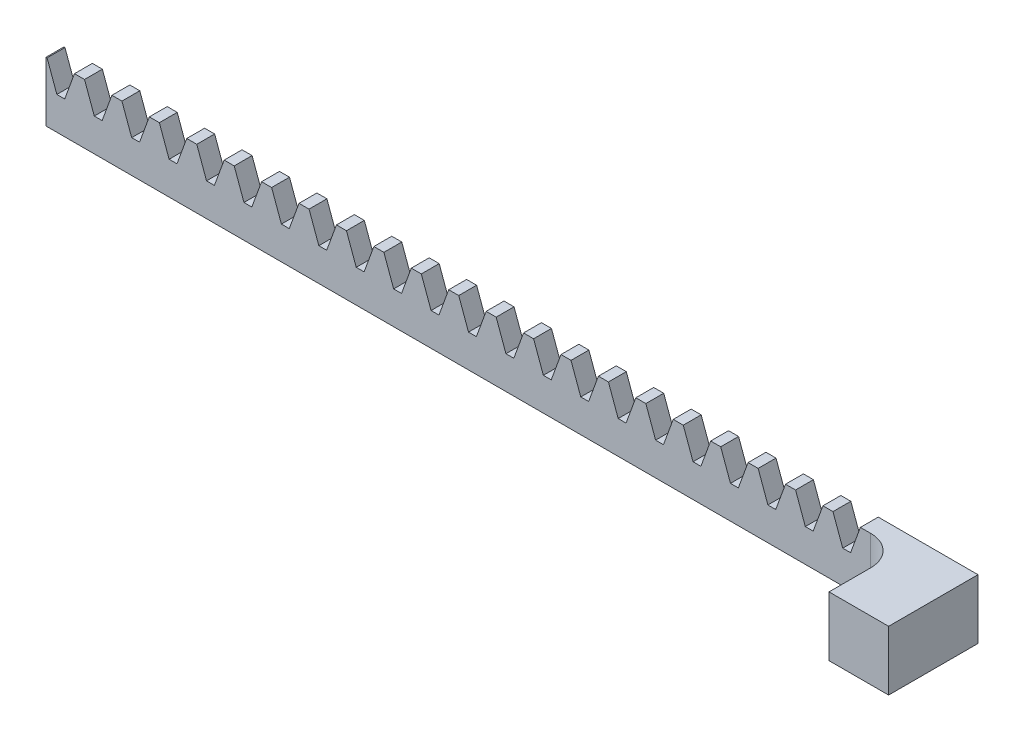
from build123d import *

# Parameters (mm, degrees)
SKETCH_1_W                 = 153.4
SKETCH_1_H                 = 10
EXTRUDE_1_DEPTH            = 3
CUT_EXTRUDE_1_DEPTH        = 4
PATTERN_LINEAR_1_COUNT     = 21
PATTERN_LINEAR_1_PITCH     = 6.28
PATTERN_LINEAR_1_COL_COUNT = 2
PATTERN_LINEAR_1_COL_PITCH = 6.28
SKETCH_3_W                 = 10
SKETCH_3_H                 = 15
EXTRUDE_2_DEPTH            = 10
FILLET_1_R                 = 5
SKETCH_4_R                 = 1.25
CUT_EXTRUDE_2_DEPTH        = 5.5


with BuildPart() as part:
    # 스케치1 → 보스-돌출1 (new body)
    with BuildSketch(Plane.XY):
        with Locations((0, 5)):
            Rectangle(SKETCH_1_W, SKETCH_1_H)
    extrude(amount=-EXTRUDE_1_DEPTH)

    # 스케치2 → 컷-돌출1 (cut, through all)
    with BuildSketch(Plane.XY):
        Polygon((-68.600074414, 5.5), (-67.279925586, 5.5), (-65.642059531, 10), (-70.237940469, 10), align=None)
    cut_extrude_1 = extrude(amount=-CUT_EXTRUDE_1_DEPTH, mode=Mode.SUBTRACT)

    # 선형 패턴1: 컷-돌출1 ×21
    with Locations(*[(i * PATTERN_LINEAR_1_PITCH, 0, 0) for i in range(1, PATTERN_LINEAR_1_COUNT)]):
        add(cut_extrude_1, mode=Mode.SUBTRACT)

    # 선형 패턴1 col: 컷-돌출1 ×2
    with Locations(*[(-i * PATTERN_LINEAR_1_COL_PITCH, 0, 0) for i in range(1, PATTERN_LINEAR_1_COL_COUNT)]):
        add(cut_extrude_1, mode=Mode.SUBTRACT)

    # 스케치3 → 보스-돌출2 (add)
    with BuildSketch(Plane.XZ):
        with Locations((71.7, 4.5)):
            Rectangle(SKETCH_3_W, SKETCH_3_H)
    extrude(amount=-EXTRUDE_2_DEPTH)

    # 필렛1
    fillet_1_edges = [part.edges().sort_by_distance(p)[0] for p in [
        (66.7, 5, 0),
    ]]
    fillet(fillet_1_edges, radius=FILLET_1_R)

    # 스케치4 → 컷-돌출2 (cut)
    with BuildSketch(Plane.XZ):
        with Locations((71.7, 9)):
            Circle(SKETCH_4_R)
    extrude(amount=-CUT_EXTRUDE_2_DEPTH, mode=Mode.SUBTRACT)


solid = part.part
